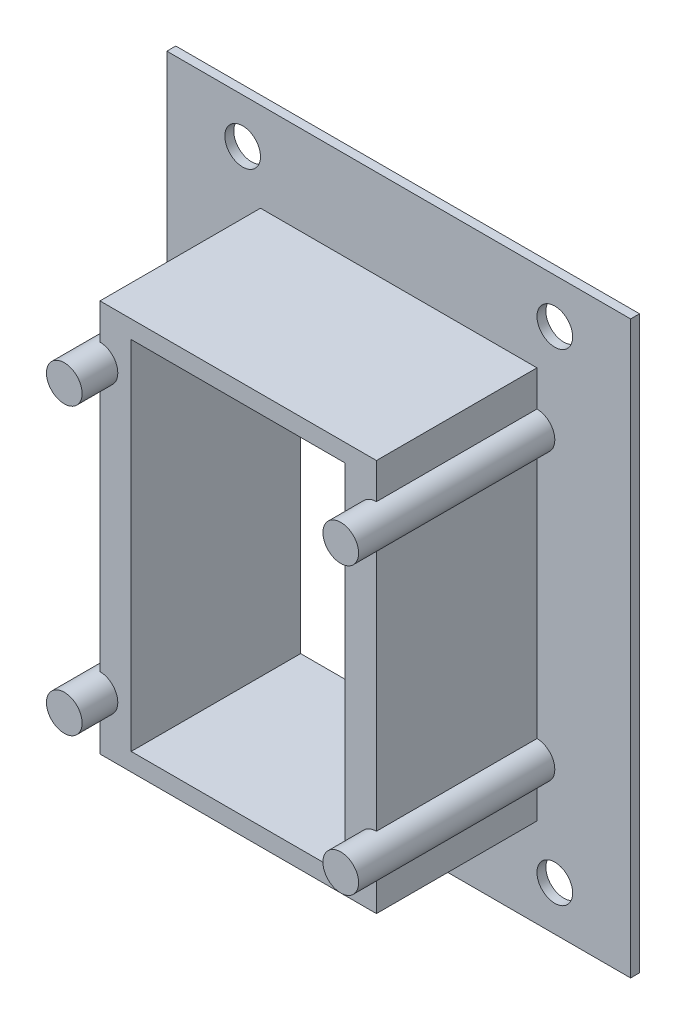
from build123d import *

# Parameters (mm, degrees)
SKETCH1_W                   = 82.55
SKETCH1_H                   = 101.6
BOSS_EXTRUDE1_DEPTH         = 1.5875
SKETCH2_W                   = 49.2125
SKETCH2_H                   = 69.85
BOSS_EXTRUDE2_DEPTH         = 28.575
SKETCH3_R                   = 3.175
BOSS_EXTRUDE3_DEPTH         = 34.925
F_1_4_0_25_DIAMETER_HOLE1_D = 6.35
SKETCH6_W                   = 38.1
SKETCH6_H                   = 63.5
CUT_EXTRUDE1_DEPTH          = 31.1625


with BuildPart() as part:
    # Sketch1 → Boss-Extrude1 (new body)
    with BuildSketch(Plane.XY):
        Rectangle(SKETCH1_W, SKETCH1_H)
    extrude(amount=BOSS_EXTRUDE1_DEPTH)

    # Sketch2 → Boss-Extrude2 (add)
    with BuildSketch(Plane.XY.offset(1.5875)):
        Rectangle(SKETCH2_W, SKETCH2_H)
    extrude(amount=BOSS_EXTRUDE2_DEPTH)

    # Sketch3 → Boss-Extrude3 (add)
    with BuildSketch(Plane.XY.offset(1.5875)):
        with Locations((-24.60625, 25.4)):
            Circle(SKETCH3_R)
        with Locations((24.60625, 25.4)):
            Circle(SKETCH3_R)
        with Locations((-24.60625, -25.4)):
            Circle(SKETCH3_R)
        with Locations((24.60625, -25.4)):
            Circle(SKETCH3_R)
    extrude(amount=BOSS_EXTRUDE3_DEPTH)

    # 1/4 (0.25) Diameter Hole1 (through all)
    with Locations(Plane.XY.offset(1.5875)):
        with Locations((-27.78125, 42.8625), (27.78125, 42.8625), (-27.78125, -42.8625), (27.78125, -42.8625)):
            Hole(F_1_4_0_25_DIAMETER_HOLE1_D / 2)

    # Sketch6 → Cut-Extrude1 (cut, through all)
    with BuildSketch(Plane.XY.offset(30.1625)):
        Rectangle(SKETCH6_W, SKETCH6_H)
    extrude(amount=-CUT_EXTRUDE1_DEPTH, mode=Mode.SUBTRACT)


solid = part.part
